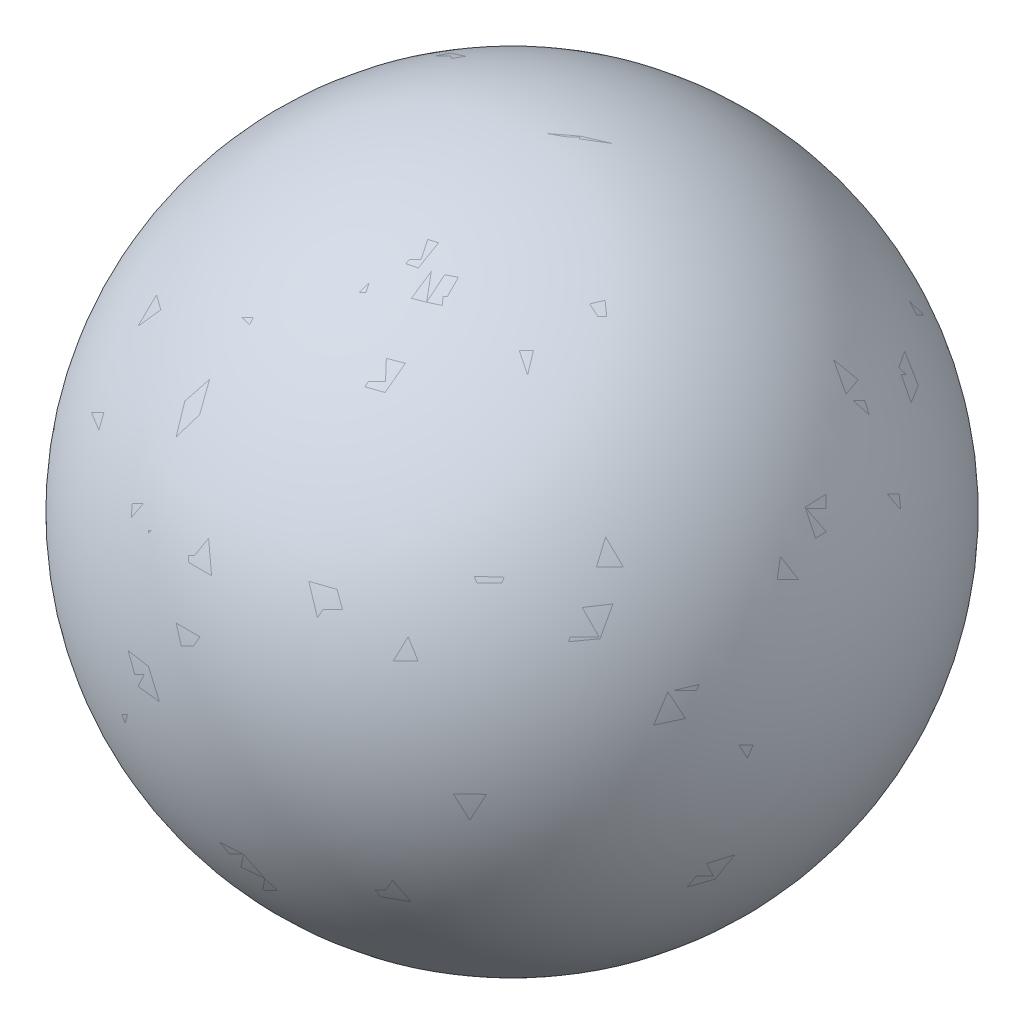
from build123d import *


with BuildPart() as part:
    # Sketch1 → Revolve1 (revolve)
    with BuildSketch(Plane.XY):
        with BuildLine():
            Line((0, 100), (0, -100))
            ThreePointArc((0, -100), (100, 0), (0, 100))
        make_face()
    revolve(axis=Axis((0, 100, 0), (0, -1, 0)))


with BuildPart() as body_2:
    # Sketch2 → Revolve2 (revolve)
    with BuildSketch(Plane.XY):
        with BuildLine():
            Line((0, 100), (0, -100))
            ThreePointArc((0, -100), (100, 0), (0, 100))
        make_face()
    revolve(axis=Axis((0, 100, 0), (0, -1, 0)))


solid = Compound([part.part, body_2.part])
